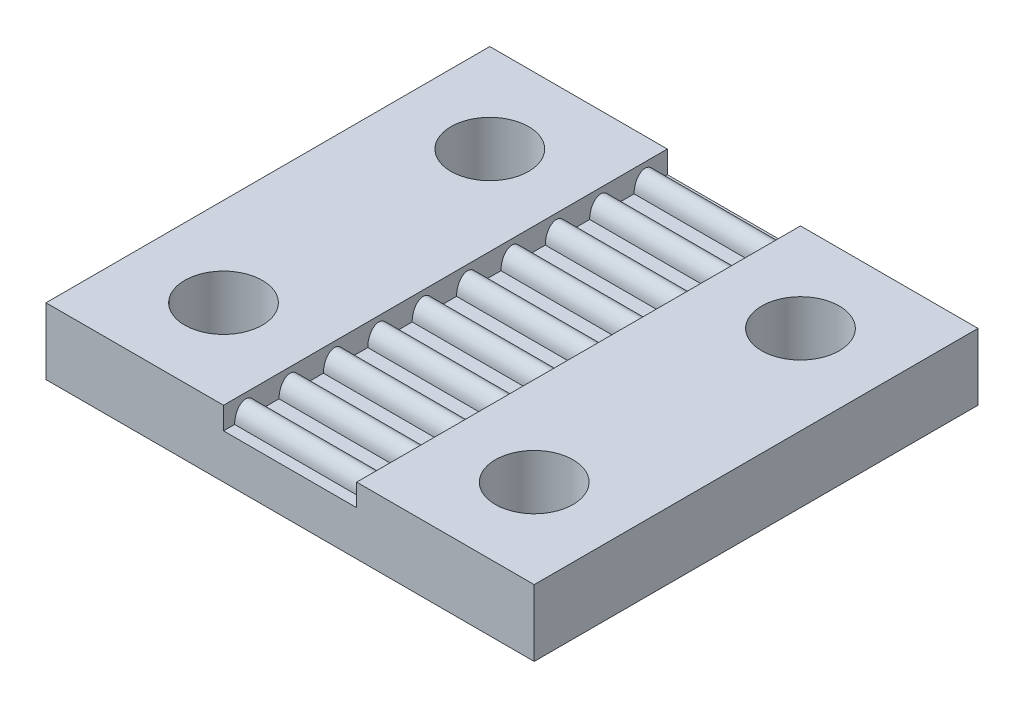
from build123d import *

# Parameters (mm, degrees)
BOSS_EXTRUDE1_DEPTH     = 10
BOSS_EXTRUDE2_START     = -11
SKETCH3_RX              = 0.75
SKETCH3_RY              = 0.5
BOSS_EXTRUDE2_DEPTH     = 14
LPATTERN1_COUNT         = 5
LPATTERN1_PITCH         = 2
LPATTERN1_COL_COUNT     = 6
LPATTERN1_COL_PITCH     = 2
SKETCH4_R               = 1.75
CUT_EXTRUDE2_DEPTH      = 2.0000001
CUT_EXTRUDE2_DEPTH_BACK = 3


with BuildPart() as part:
    # Sketch2 → Boss-Extrude1 (new body, symmetric)
    with BuildSketch(Plane.XY):
        Polygon((-11, 1), (-3, 1), (-3, 0), (3, 0), (3, 1), (11, 1), (11, -2), (-11, -2), align=None)
    extrude(amount=BOSS_EXTRUDE1_DEPTH, both=True)

    # Sketch3 → Boss-Extrude2 (add)
    with BuildSketch(Plane(origin=(0, 0, 0), x_dir=(0, 0, -1), z_dir=(1, 0, 0)).offset(BOSS_EXTRUDE2_START)):
        with Locations(Location((-1, 0), (0, 0, 90))):
            Ellipse(SKETCH3_RX, SKETCH3_RY)
    boss_extrude2 = extrude(amount=BOSS_EXTRUDE2_DEPTH)

    # LPattern1: Boss-Extrude2 ×5
    with Locations(*[(0, 0, i * LPATTERN1_PITCH) for i in range(1, LPATTERN1_COUNT)]):
        add(boss_extrude2)

    # LPattern1 col: Boss-Extrude2 ×6
    with Locations(*[(0, 0, -i * LPATTERN1_COL_PITCH) for i in range(1, LPATTERN1_COL_COUNT)]):
        add(boss_extrude2)

    # Sketch4 → Cut-Extrude2 (cut, two sides)
    with BuildSketch(Plane(origin=(0, 0, 0), x_dir=(1, 0, 0), z_dir=(0, 1, 0))) as cut_extrude2_sk:
        with Locations((-7, 6)):
            Circle(SKETCH4_R)
        with Locations((7, 6)):
            Circle(SKETCH4_R)
        with Locations((7, -6)):
            Circle(SKETCH4_R)
        with Locations((-7, -6)):
            Circle(SKETCH4_R)
    extrude(amount=CUT_EXTRUDE2_DEPTH, mode=Mode.SUBTRACT)
    extrude(cut_extrude2_sk.sketch, amount=-CUT_EXTRUDE2_DEPTH_BACK, mode=Mode.SUBTRACT)


solid = part.part
